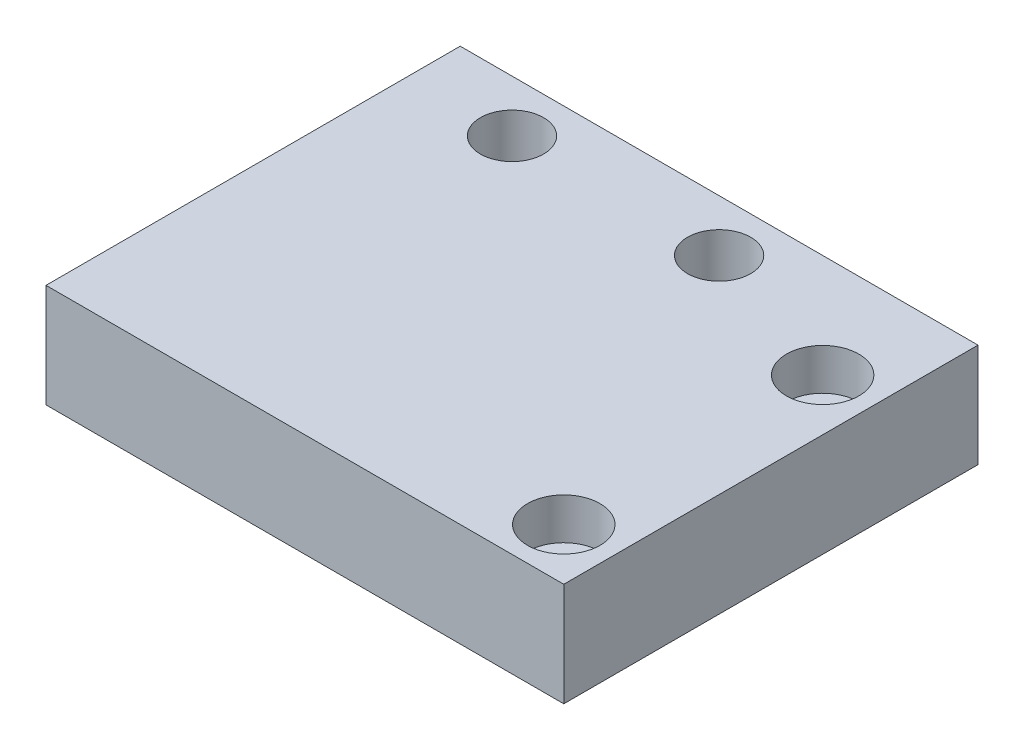
from build123d import *

# Parameters (mm, degrees)
SKETCH1_W           = 50
SKETCH1_H           = 40
BOSS_EXTRUDE1_DEPTH = 10
SKETCH2_R           = 2.05
CUT_EXTRUDE1_DEPTH  = 10
SKETCH4_R           = 3.05
CUT_EXTRUDE2_DEPTH  = 10
SKETCH5_R           = 2
CUT_EXTRUDE3_DEPTH  = 10
SKETCH6_R           = 3.5
CUT_EXTRUDE4_DEPTH  = 4
SKETCH7_R           = 3.5
CUT_EXTRUDE5_DEPTH  = 4


with BuildPart() as part:
    # Sketch1 → Boss-Extrude1 (new body)
    with BuildSketch(Plane(origin=(0, 0, 0), x_dir=(1, 0, 0), z_dir=(0, 1, 0))):
        Rectangle(SKETCH1_W, SKETCH1_H)
    extrude(amount=BOSS_EXTRUDE1_DEPTH)

    # Sketch2 → Cut-Extrude1 (cut)
    with BuildSketch(Plane(origin=(0, 10, 0), x_dir=(1, 0, 0), z_dir=(0, 1, 0))):
        with Locations((20, 10)):
            Circle(SKETCH2_R)
    extrude(amount=-CUT_EXTRUDE1_DEPTH, mode=Mode.SUBTRACT)

    # Sketch4 → Cut-Extrude2 (cut)
    with BuildSketch(Plane(origin=(0, 10, 0), x_dir=(1, 0, 0), z_dir=(0, 1, 0))):
        with Locations((-15, 15)):
            Circle(SKETCH4_R)
        with Locations((5, 15)):
            Circle(SKETCH4_R)
    extrude(amount=-CUT_EXTRUDE2_DEPTH, mode=Mode.SUBTRACT)

    # Sketch5 → Cut-Extrude3 (cut)
    with BuildSketch(Plane(origin=(0, 10, 0), x_dir=(1, 0, 0), z_dir=(0, 1, 0))):
        with Locations((20, -15)):
            Circle(SKETCH5_R)
    extrude(amount=-CUT_EXTRUDE3_DEPTH, mode=Mode.SUBTRACT)

    # Sketch6 → Cut-Extrude4 (cut)
    with BuildSketch(Plane(origin=(0, 10, 0), x_dir=(1, 0, 0), z_dir=(0, 1, 0))):
        with Locations((20, 10)):
            Circle(SKETCH6_R)
    extrude(amount=-CUT_EXTRUDE4_DEPTH, mode=Mode.SUBTRACT)

    # Sketch7 → Cut-Extrude5 (cut)
    with BuildSketch(Plane(origin=(0, 10, 0), x_dir=(1, 0, 0), z_dir=(0, 1, 0))):
        with Locations((20, -15)):
            Circle(SKETCH7_R)
    extrude(amount=-CUT_EXTRUDE5_DEPTH, mode=Mode.SUBTRACT)


solid = part.part
